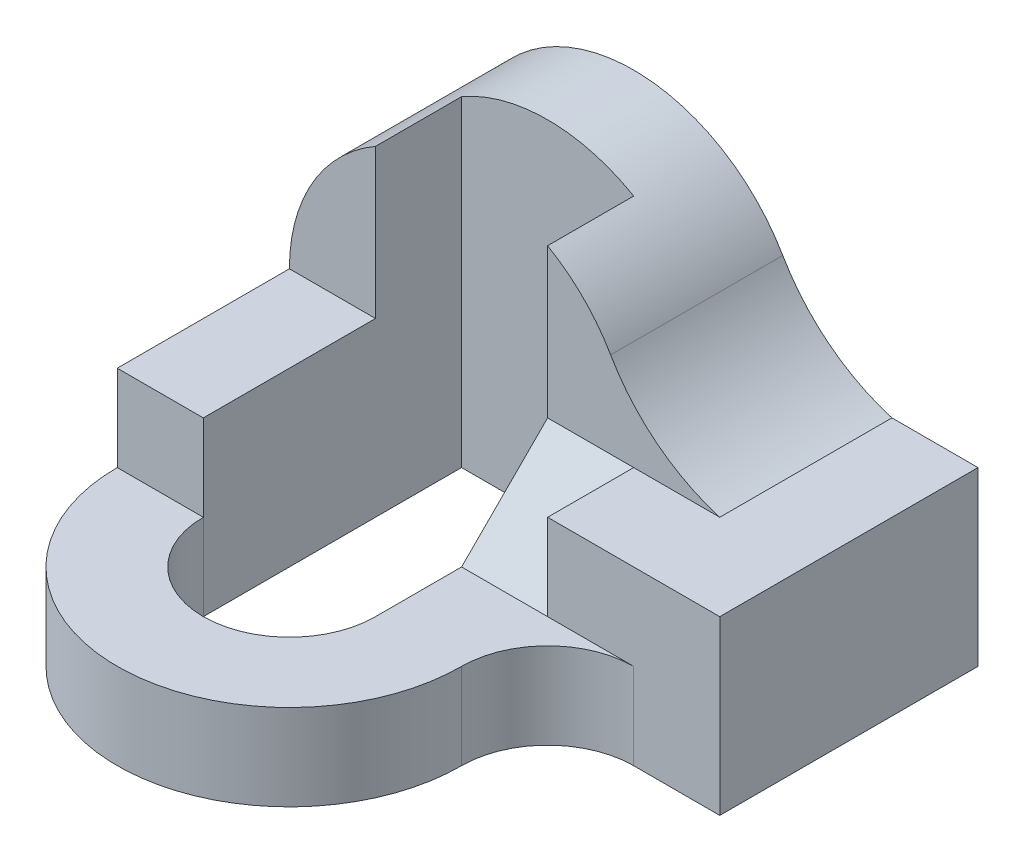
from build123d import *

# Parameters (mm, degrees)
SKETCH1_W           = 6
SKETCH1_H           = 2
BOSS_EXTRUDE2_DEPTH = 3
BOSS_EXTRUDE3_DEPTH = 2
CUT_EXTRUDE2_DEPTH  = 2
CUT_EXTRUDE3_DEPTH  = 1
BOSS_EXTRUDE5_DEPTH = 2
CUT_EXTRUDE4_DEPTH  = 1


with BuildPart() as part:
    # Sketch1 → Boss-Extrude2 (new body)
    with BuildSketch(Plane.XY):
        Rectangle(SKETCH1_W, SKETCH1_H)
    extrude(amount=BOSS_EXTRUDE2_DEPTH)

    # Sketch3 → Boss-Extrude3 (add)
    with BuildSketch(Plane(origin=(0, 0, 0), x_dir=(-1, 0, 0), z_dir=(0, 0, -1))):
        with BuildLine():
            Line((-2, 1), (3, 1))
            ThreePointArc((3, 1), (1.51763809, 2.931851653), (-0.732050808, 2))
            ThreePointArc((-0.732050808, 2), (-1.270020956, 1.378271238), (-2, 1))
        make_face()
    extrude(amount=-BOSS_EXTRUDE3_DEPTH)

    # Sketch4 → Cut-Extrude2 (cut)
    with BuildSketch(Plane.XY.offset(3)):
        with BuildLine():
            Line((0, -1), (0, 2.732050808))
            ThreePointArc((0, 2.732050808), (-1, 3), (-2, 2.732050808))
            Line((-2, 2.732050808), (-2, -1))
            Line((-2, -1), (0, -1))
        make_face()
    extrude(amount=-CUT_EXTRUDE2_DEPTH, mode=Mode.SUBTRACT)

    # Sketch5 → Cut-Extrude3 (cut)
    with BuildSketch(Plane.ZY):
        Polygon((2, 1), (3, 0), (3, 1), align=None)
    extrude(amount=-CUT_EXTRUDE3_DEPTH, mode=Mode.SUBTRACT)

    # Sketch6 → Boss-Extrude5 (add)
    with BuildSketch(Plane(origin=(0, 1, 0), x_dir=(1, 0, 0), z_dir=(0, 1, 0))):
        with BuildLine():
            ThreePointArc((-3, -4), (-1, -6), (1, -4))
            ThreePointArc((1, -4), (1.292893219, -3.292893219), (2, -3))
            Line((2, -3), (0, -3))
            Line((0, -3), (0, -4))
            ThreePointArc((0, -4), (-1, -5), (-2, -4))
            Line((-2, -4), (-2, -3))
            Line((-2, -3), (-3, -3))
            Line((-3, -3), (-3, -4))
        make_face()
    extrude(amount=-BOSS_EXTRUDE5_DEPTH)

    # Sketch7 → Cut-Extrude4 (cut)
    with BuildSketch(Plane(origin=(0, 1, 0), x_dir=(1, 0, 0), z_dir=(0, 1, 0))):
        with BuildLine():
            Line((-2, -4), (-3, -4))
            ThreePointArc((-3, -4), (-1, -6), (1, -4))
            ThreePointArc((1, -4), (1.292893219, -3.292893219), (2, -3))
            Line((2, -3), (0, -3))
            Line((0, -3), (0, -4))
            ThreePointArc((0, -4), (-1, -5), (-2, -4))
        make_face()
    extrude(amount=-CUT_EXTRUDE4_DEPTH, mode=Mode.SUBTRACT)


solid = part.part
